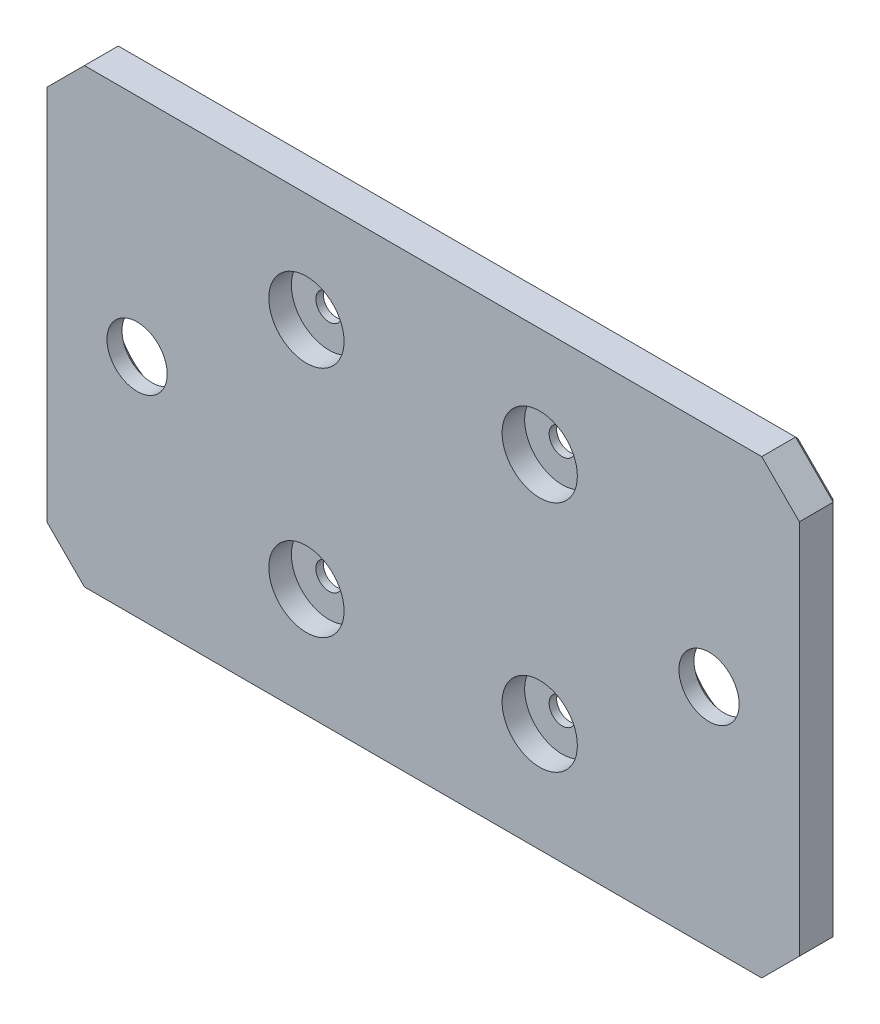
from build123d import *

# Parameters (mm, degrees)
SKETCH1_W               = 100
SKETCH1_H               = 60
BOSS_EXTRUDE1_DEPTH     = 5
SKETCH3_W               = 43.5
SKETCH3_H               = 43.5
CUT_EXTRUDE1_DEPTH      = 1
SKETCH4_R               = 1.75
CUT_EXTRUDE3_DEPTH      = 92
CUT_EXTRUDE3_DEPTH_BACK = 1
SKETCH5_R               = 5
CUT_EXTRUDE4_DEPTH      = 3
SKETCH6_R               = 4
CUT_EXTRUDE5_DEPTH      = 1
CUT_EXTRUDE5_DEPTH_BACK = 6
SKETCH7_R               = 7.5
CUT_EXTRUDE6_DEPTH      = 3
CHAMFER1_SIZE           = 0.5
CHAMFER2_SIZE           = 5
CHAMFER3_SIZE           = 0.5


with BuildPart() as part:
    # Sketch1 → Boss-Extrude1 (new body)
    with BuildSketch(Plane.XY):
        Rectangle(SKETCH1_W, SKETCH1_H)
    extrude(amount=BOSS_EXTRUDE1_DEPTH)

    # Sketch3 → Cut-Extrude1 (cut)
    with BuildSketch(Plane.XY):
        Rectangle(SKETCH3_W, SKETCH3_H)
    extrude(amount=CUT_EXTRUDE1_DEPTH, mode=Mode.SUBTRACT)

    # Sketch4 → Cut-Extrude3 (cut, two sides)
    with BuildSketch(Plane.XY.offset(-48)) as cut_extrude3_sk:
        with Locations((-15.5, 15.5)):
            Circle(SKETCH4_R)
        with Locations((15.5, 15.5)):
            Circle(SKETCH4_R)
        with Locations((15.499999999, -15.5)):
            Circle(SKETCH4_R)
        with Locations((-15.5, -15.5)):
            Circle(SKETCH4_R)
    extrude(amount=CUT_EXTRUDE3_DEPTH, mode=Mode.SUBTRACT)
    extrude(cut_extrude3_sk.sketch, amount=-CUT_EXTRUDE3_DEPTH_BACK, mode=Mode.SUBTRACT)

    # Sketch5 → Cut-Extrude4 (cut)
    with BuildSketch(Plane.XY.offset(5)):
        with Locations((-15.5, 15.5)):
            Circle(SKETCH5_R)
        with Locations((15.5, 15.5)):
            Circle(SKETCH5_R)
        with Locations((15.499999999, -15.5)):
            Circle(SKETCH5_R)
        with Locations((-15.5, -15.5)):
            Circle(SKETCH5_R)
    extrude(amount=-CUT_EXTRUDE4_DEPTH, mode=Mode.SUBTRACT)

    # Sketch6 → Cut-Extrude5 (cut, two sides)
    with BuildSketch(Plane(origin=(0, 0, 0), x_dir=(-1, 0, 0), z_dir=(0, 0, -1))) as cut_extrude5_sk:
        with Locations((-38, 0)):
            Circle(SKETCH6_R)
        with Locations((38, 0)):
            Circle(SKETCH6_R)
    extrude(amount=CUT_EXTRUDE5_DEPTH, mode=Mode.SUBTRACT)
    extrude(cut_extrude5_sk.sketch, amount=-CUT_EXTRUDE5_DEPTH_BACK, mode=Mode.SUBTRACT)

    # Sketch7 → Cut-Extrude6 (cut)
    with BuildSketch(Plane(origin=(0, 0, 0), x_dir=(-1, 0, 0), z_dir=(0, 0, -1))):
        with Locations((-38, 0)):
            Circle(SKETCH7_R)
        with Locations((38, 0)):
            Circle(SKETCH7_R)
    extrude(amount=-CUT_EXTRUDE6_DEPTH, mode=Mode.SUBTRACT)

    # Chamfer1
    chamfer1_edges = [part.edges().sort_by_distance(p)[0] for p in [
        (45.5, 0, 0),
        (-30.5, 0, 0),
    ]]
    chamfer(chamfer1_edges, length=CHAMFER1_SIZE)

    # Chamfer2
    chamfer2_edges = [part.edges().sort_by_distance(p)[0] for p in [
        (50, -30, 2.5),
        (-50, -30, 2.5),
        (-50, 30, 2.5),
        (50, 30, 2.5),
    ]]
    chamfer(chamfer2_edges, length=CHAMFER2_SIZE)

    # Chamfer3
    chamfer3_edges = [part.edges().sort_by_distance(p)[0] for p in [
        (0, 30, 0),
        (50, 0, 0),
        (0, -30, 0),
        (-50, 0, 0),
        (47.5, -27.5, 0),
        (-47.5, -27.5, 0),
        (-47.5, 27.5, 0),
        (47.5, 27.5, 0),
    ]]
    chamfer(chamfer3_edges, length=CHAMFER3_SIZE)


solid = part.part
